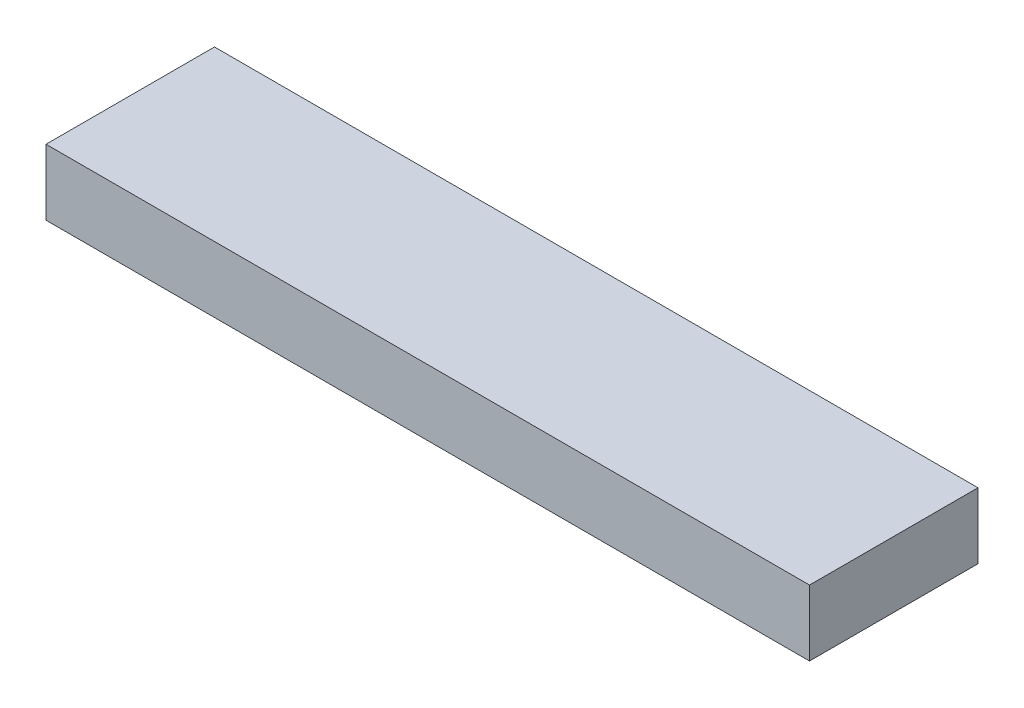
from build123d import *

# Parameters (mm, degrees)
SKETCH1_W           = 290
SKETCH1_H           = 64
BOSS_EXTRUDE1_DEPTH = 25


with BuildPart() as part:
    # Sketch1 → Boss-Extrude1 (new body)
    with BuildSketch(Plane(origin=(0, 0, 0), x_dir=(1, 0, 0), z_dir=(0, 1, 0))):
        Rectangle(SKETCH1_W, SKETCH1_H)
    extrude(amount=-BOSS_EXTRUDE1_DEPTH)


solid = part.part
